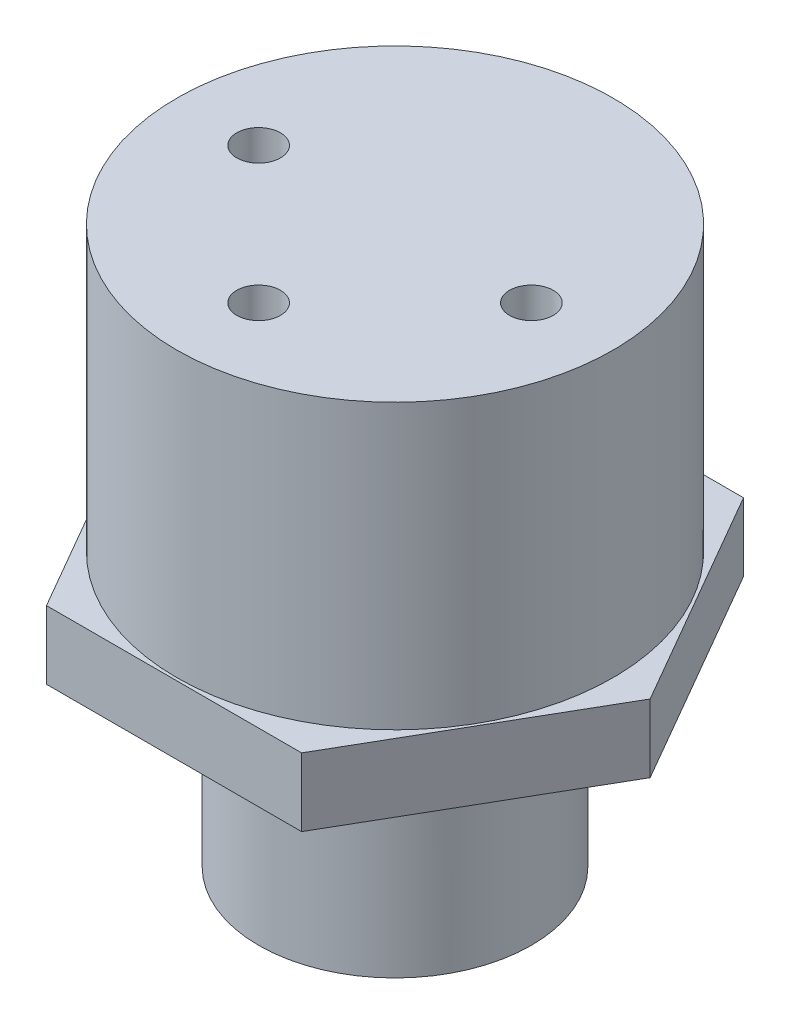
from build123d import *

# Parameters (mm, degrees)
SKETCH1_R           = 20.32
BOSS_EXTRUDE1_DEPTH = 26.416
BOSS_EXTRUDE2_DEPTH = 6.35
SKETCH3_R           = 12.7
BOSS_EXTRUDE3_DEPTH = 19.05
SKETCH4_R           = 2.032
CUT_EXTRUDE1_DEPTH  = 10.16


with BuildPart() as part:
    # Sketch1 → Boss-Extrude1 (new body)
    with BuildSketch(Plane(origin=(0, 0, 0), x_dir=(1, 0, 0), z_dir=(0, 1, 0))):
        Circle(SKETCH1_R)
    extrude(amount=BOSS_EXTRUDE1_DEPTH)

    # Sketch2 → Boss-Extrude2 (add)
    with BuildSketch(Plane.XZ):
        Polygon((-11.878404438, 20.574), (11.878404438, 20.574), (23.756808877, 0), (11.878404438, -20.574), (-11.878404438, -20.574), (-23.756808877, 0), align=None)
    extrude(amount=BOSS_EXTRUDE2_DEPTH)

    # Sketch3 → Boss-Extrude3 (add)
    with BuildSketch(Plane(origin=(0, -6.35, 0), x_dir=(-1, 0, 0), z_dir=(0, -1, 0))):
        Circle(SKETCH3_R)
    extrude(amount=BOSS_EXTRUDE3_DEPTH)

    # Sketch4 → Cut-Extrude1 (cut)
    with BuildSketch(Plane(origin=(0, 26.416, 0), x_dir=(1, 0, 0), z_dir=(0, 1, 0))):
        with Locations((0, -12.7)):
            Circle(SKETCH4_R)
        with Locations((-12.7, 0)):
            Circle(SKETCH4_R)
        with Locations((12.7, 0)):
            Circle(SKETCH4_R)
    extrude(amount=-CUT_EXTRUDE1_DEPTH, mode=Mode.SUBTRACT)


solid = part.part
